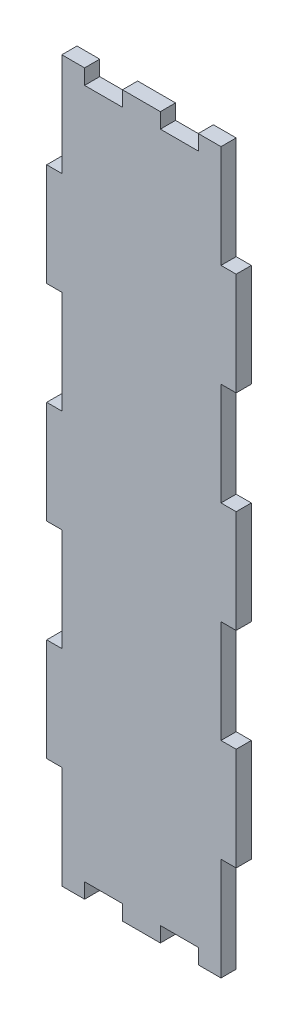
from build123d import *

# Parameters (mm, degrees)
BUITENAFMETING_RECHTHOEK_W  = 50
BUITENAFMETING_RECHTHOEK_H  = 190
PLAAT_DEPTH                 = 4
TAND_HOR_W                  = 10
TAND_HOR_H                  = 4
TAND_BOVEN_DEPTH            = 5
TANDEN_PATROON_BOVEN_COUNT  = 2
TANDEN_PATROON_BOVEN_PITCH  = 20
TAND_VER_W                  = 4
TAND_VER_H                  = 27.142857143
TAND_LINKS_DEPTH            = 5
TANDEN_PATROON_LINKS_COUNT  = 4
TANDEN_PATROON_LINKS_PITCH  = 54.285714286
TAND_O_W                    = 10
TAND_O_H                    = 4
TAND_ONDER_DEPTH            = 5
TANDEN_PATROON_ONDER_COUNT  = 2
TANDEN_PATROON_ONDER_PITCH  = 20
TAND_R_W                    = 4
TAND_R_H                    = 27.142857143
TAND_RECHTS_DEPTH           = 5
TANDEN_PATROON_RECHTS_COUNT = 4
TANDEN_PATROON_RECHTS_PITCH = 54.285714286


with BuildPart() as part:
    # Buitenafmeting Rechthoek → Plaat (new body)
    with BuildSketch(Plane.XY):
        with Locations((25, 95)):
            Rectangle(BUITENAFMETING_RECHTHOEK_W, BUITENAFMETING_RECHTHOEK_H)
    extrude(amount=-PLAAT_DEPTH)

    # Tand Hor → Tand Boven (cut, through all)
    with BuildSketch(Plane.XY):
        with Locations((15, 188)):
            Rectangle(TAND_HOR_W, TAND_HOR_H)
    tand_boven = extrude(amount=-TAND_BOVEN_DEPTH, mode=Mode.SUBTRACT)

    # Tanden Patroon Boven: Tand Boven ×2
    with Locations(*[(i * TANDEN_PATROON_BOVEN_PITCH, 0, 0) for i in range(1, TANDEN_PATROON_BOVEN_COUNT)]):
        add(tand_boven, mode=Mode.SUBTRACT)

    # Tand Ver → Tand Links (cut, through all)
    with BuildSketch(Plane.XY):
        with Locations((2, 176.428571428)):
            Rectangle(TAND_VER_W, TAND_VER_H)
    tand_links = extrude(amount=-TAND_LINKS_DEPTH, mode=Mode.SUBTRACT)

    # Tanden Patroon Links: Tand Links ×4
    with Locations(*[(0, -i * TANDEN_PATROON_LINKS_PITCH, 0) for i in range(1, TANDEN_PATROON_LINKS_COUNT)]):
        add(tand_links, mode=Mode.SUBTRACT)

    # Tand O → Tand Onder (cut, through all)
    with BuildSketch(Plane.XY):
        with Locations((15, 2)):
            Rectangle(TAND_O_W, TAND_O_H)
    tand_onder = extrude(amount=-TAND_ONDER_DEPTH, mode=Mode.SUBTRACT)

    # Tanden Patroon Onder: Tand Onder ×2
    with Locations(*[(i * TANDEN_PATROON_ONDER_PITCH, 0, 0) for i in range(1, TANDEN_PATROON_ONDER_COUNT)]):
        add(tand_onder, mode=Mode.SUBTRACT)

    # Tand R → Tand Rechts (cut, through all)
    with BuildSketch(Plane.XY):
        with Locations((48, 176.428571428)):
            Rectangle(TAND_R_W, TAND_R_H)
    tand_rechts = extrude(amount=-TAND_RECHTS_DEPTH, mode=Mode.SUBTRACT)

    # Tanden Patroon Rechts: Tand Rechts ×4
    with Locations(*[(0, -i * TANDEN_PATROON_RECHTS_PITCH, 0) for i in range(1, TANDEN_PATROON_RECHTS_COUNT)]):
        add(tand_rechts, mode=Mode.SUBTRACT)


solid = part.part
